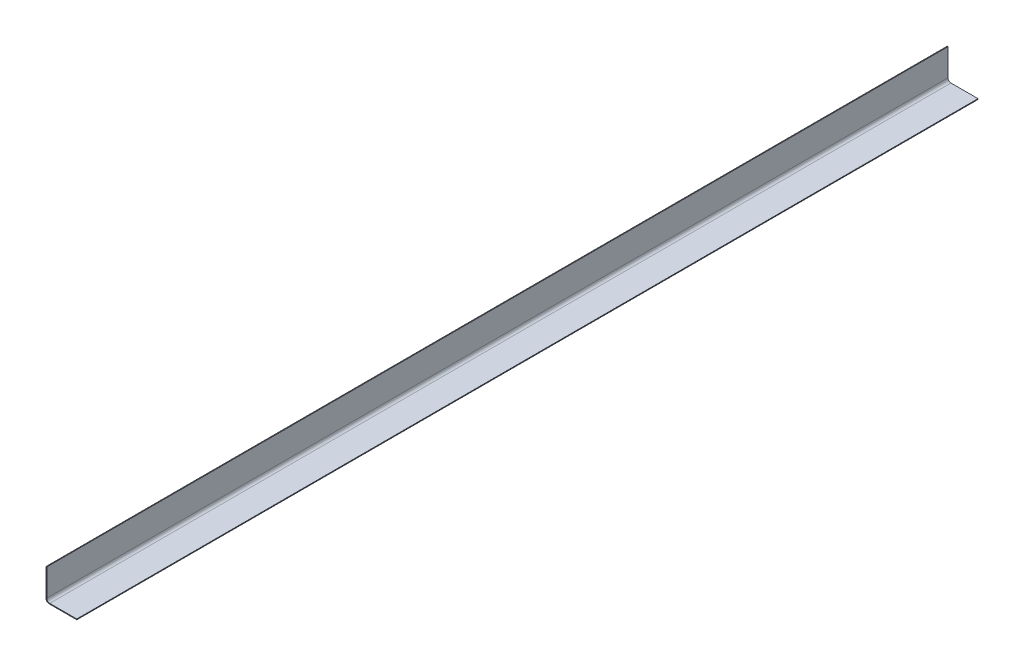
from build123d import *

# Parameters (mm, degrees)
BOSS_EXTRUDE1_DEPTH = 1200


with BuildPart() as part:
    # Sketch1 → Boss-Extrude1 (new body)
    with BuildSketch(Plane.XY):
        with BuildLine():
            Line((4, 0), (40, 0))
            Line((40, 0), (40, -1))
            Line((40, -1), (3, -1))
            ThreePointArc((3, -1), (0.171572875, 0.171572875), (-1, 3))
            Line((-1, 3), (-1, 40))
            Line((-1, 40), (0, 40))
            Line((0, 40), (0, 4))
            ThreePointArc((0, 4), (1.171572875, 1.171572875), (4, 0))
        make_face()
    extrude(amount=BOSS_EXTRUDE1_DEPTH)


solid = part.part
